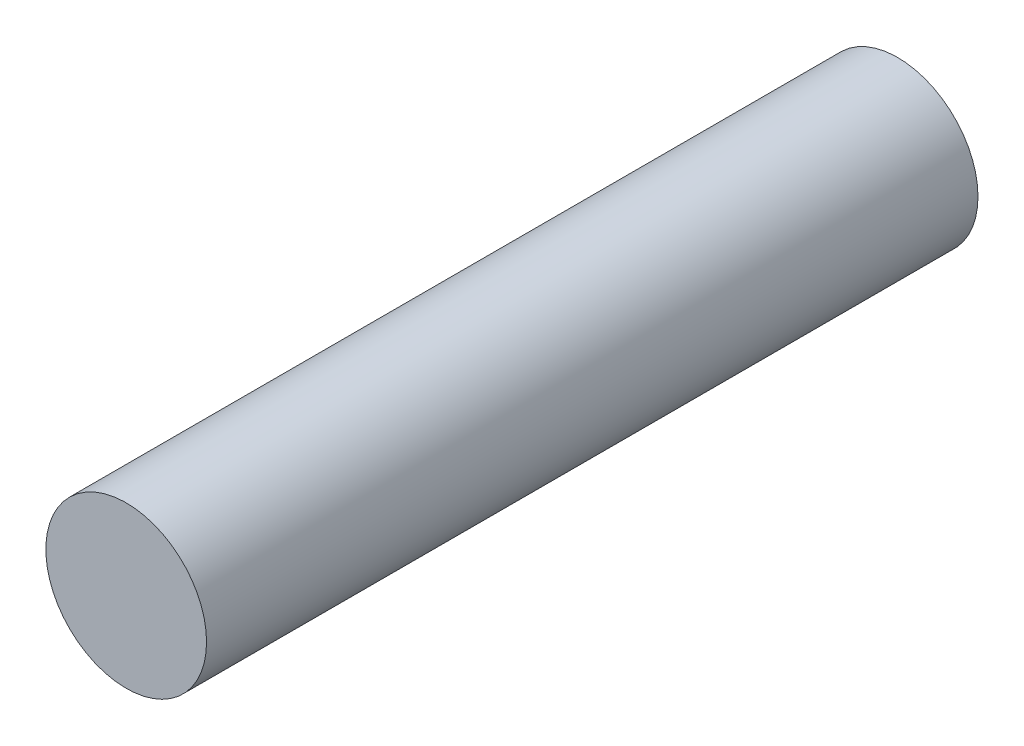
from build123d import *

# Parameters (mm, degrees)
SKETCH_1_R      = 1.25
EXTRUDE_1_DEPTH = 12


with BuildPart() as part:
    # 草图1 → 凸台-拉伸1 (new body)
    with BuildSketch(Plane.XY):
        Circle(SKETCH_1_R)
    extrude(amount=EXTRUDE_1_DEPTH)


solid = part.part
